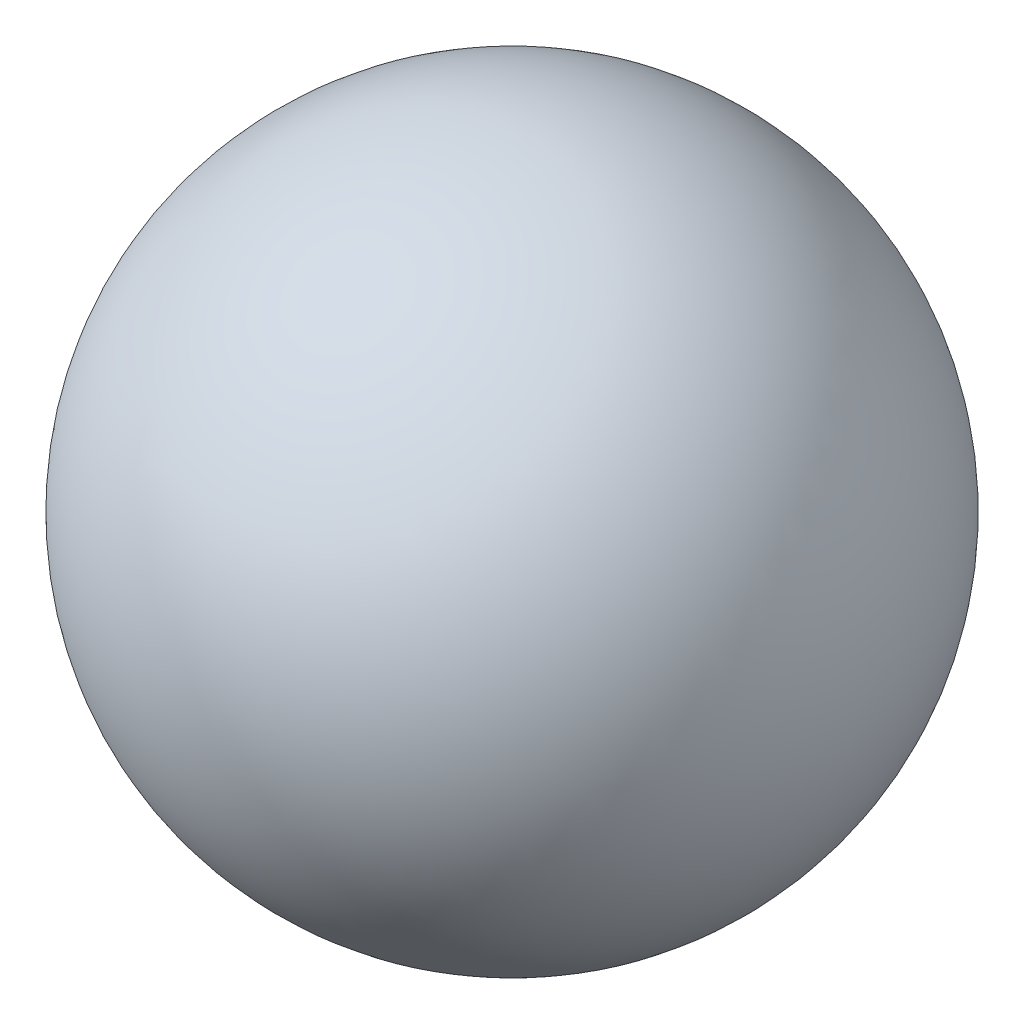
from build123d import *


with BuildPart() as part:
    # Skica1 → Rotovat3 (revolve)
    with BuildSketch(Plane.XY):
        with BuildLine():
            Line((0, 2.5), (0, -2.5))
            ThreePointArc((0, -2.5), (-2.5, 0), (0, 2.5))
        make_face()
    revolve(axis=Axis((0, 2.5, 0), (0, -1, 0)))


solid = part.part
